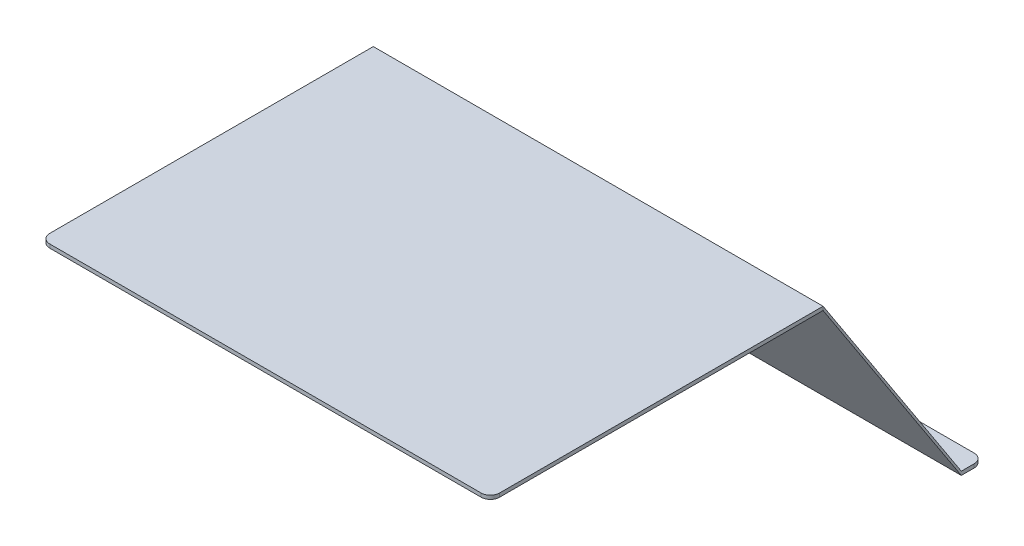
from build123d import *

# Parameters (mm, degrees)
SKETCH2_W           = 361
SKETCH2_H           = 4
BOSS_EXTRUDE1_DEPTH = 488
BOSS_EXTRUDE2_DEPTH = 488
SKETCH4_W           = 488
SKETCH4_H           = 4
BOSS_EXTRUDE3_DEPTH = 24
FILLET2_R           = 10
FILLET3_R           = 10


with BuildPart() as part:
    # Sketch2 → Boss-Extrude1 (new body)
    with BuildSketch(Plane(origin=(0, 0, 0), x_dir=(0, 0, -1), z_dir=(1, 0, 0))):
        with Locations((180.5, 2)):
            Rectangle(SKETCH2_W, SKETCH2_H)
    extrude(amount=BOSS_EXTRUDE1_DEPTH)

    # Fillet3
    fillet3_edges = [part.edges().sort_by_distance(p)[0] for p in [
        (488, 2, 0),
        (0, 2, 0),
    ]]
    fillet(fillet3_edges, radius=FILLET3_R)


with BuildPart() as body_2:
    # Sketch3 → Boss-Extrude2 (new body)
    with BuildSketch(Plane(origin=(488, 0, 0), x_dir=(0, 0, -1), z_dir=(1, 0, 0))):
        Polygon((361, 4), (511, -226), (511, -230), (361, 0), align=None)
    extrude(amount=-BOSS_EXTRUDE2_DEPTH)

    # Sketch4 → Boss-Extrude3 (add)
    with BuildSketch(Plane(origin=(0, 0, -511), x_dir=(-1, 0, 0), z_dir=(0, 0, -1))):
        with Locations((-244, -228)):
            Rectangle(SKETCH4_W, SKETCH4_H)
    extrude(amount=BOSS_EXTRUDE3_DEPTH)

    # Fillet2
    fillet2_edges = [body_2.edges().sort_by_distance(p)[0] for p in [
        (0, -228, -535),
        (488, -228, -535),
    ]]
    fillet(fillet2_edges, radius=FILLET2_R)


solid = Compound([part.part, body_2.part])
